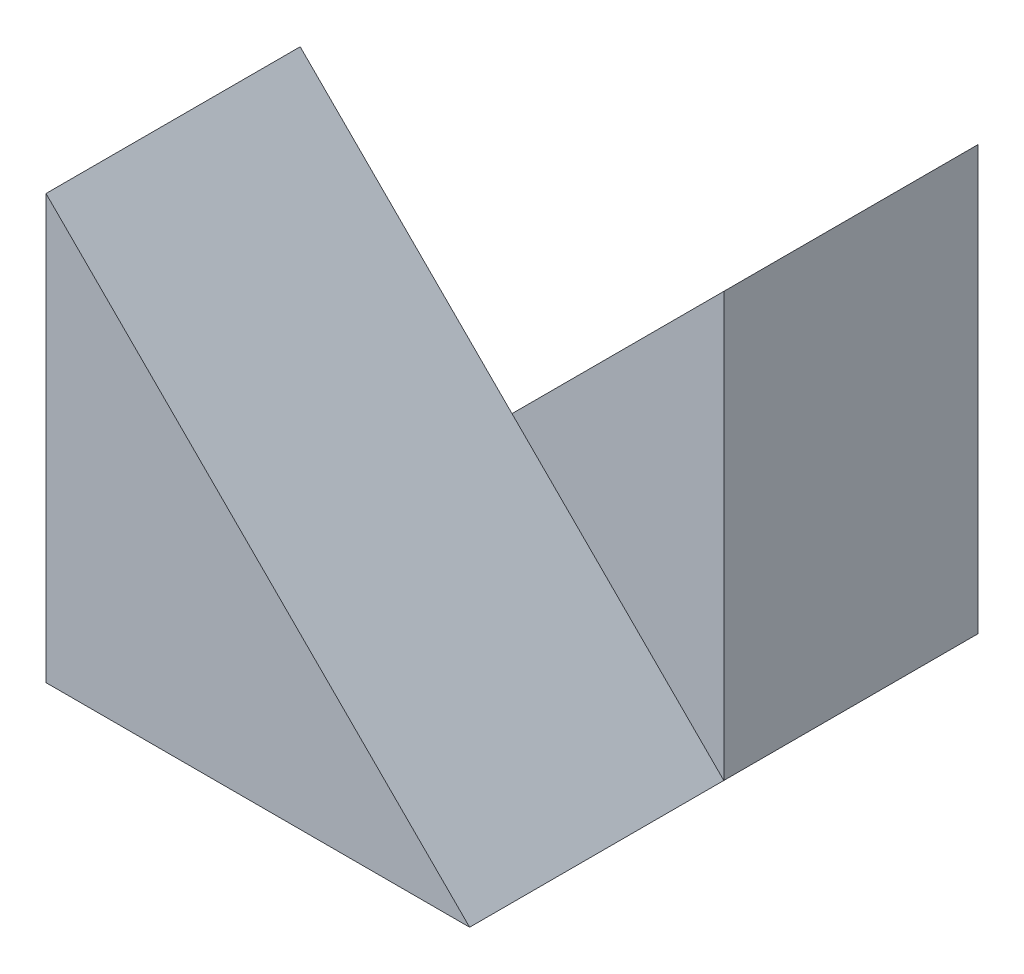
from build123d import *

# Parameters (mm, degrees)
BOSS_EXTRUDE1_DEPTH = 15
BOSS_EXTRUDE2_DEPTH = 15


with BuildPart() as part:
    # Sketch1 → Boss-Extrude1 (new body)
    with BuildSketch(Plane.XY):
        Polygon((0, 25), (0, 0), (25, 0), align=None)
    extrude(amount=BOSS_EXTRUDE1_DEPTH)

    # Sketch2 → Boss-Extrude2 (add)
    with BuildSketch(Plane(origin=(0, 0, 0), x_dir=(-1, 0, 0), z_dir=(0, 0, -1))):
        Polygon((-25, 0), (-25, 25), (0, 0), align=None)
    extrude(amount=BOSS_EXTRUDE2_DEPTH)


solid = part.part
